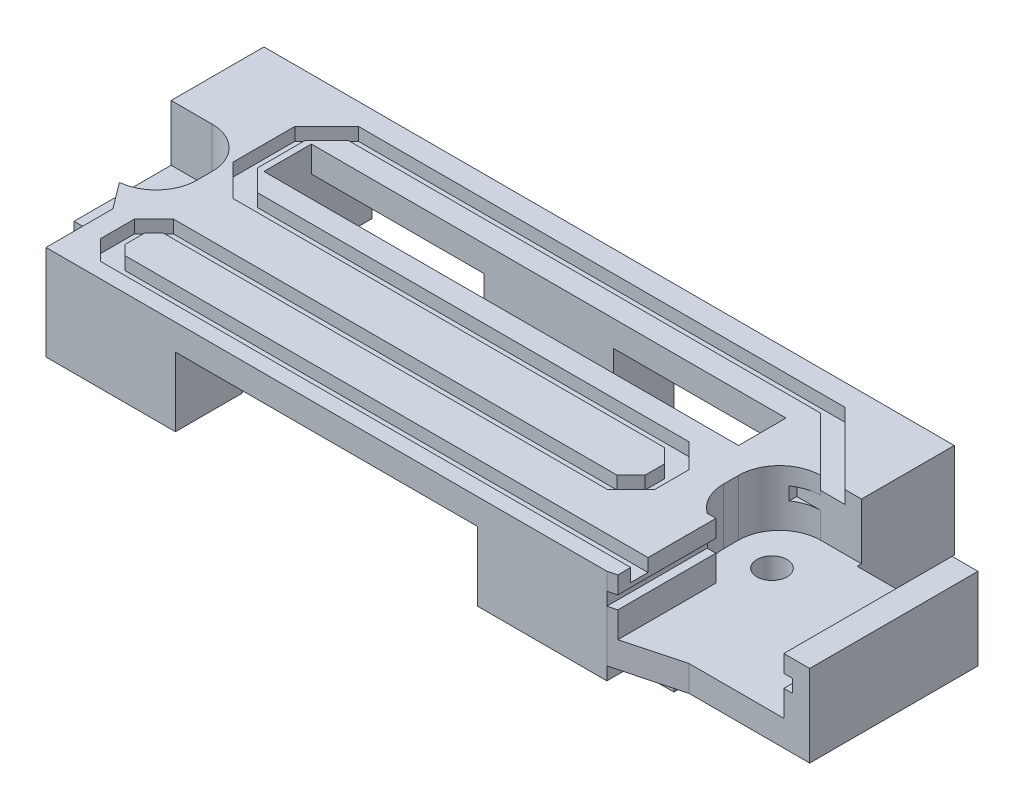
from build123d import *

# Parameters (mm, degrees)
BOSS_EXTRUDE1_DEPTH = 16
SKETCH2_W           = 15
SKETCH2_H           = 7.75
SKETCH2_W_2         = 12.5
CUT_EXTRUDE1_DEPTH  = 5
CUT_EXTRUDE4_DEPTH  = 13
SKETCH6_W           = 55
SKETCH6_H           = 5.5
CUT_EXTRUDE5_DEPTH  = 3
SKETCH7_W           = 15
SKETCH7_H           = 7
SKETCH7_H_2         = 3
BOSS_EXTRUDE2_DEPTH = 13.25
SKETCH8_R           = 2.5
CUT_EXTRUDE6_DEPTH  = 15.5
SKETCH9_R           = 1.75
CUT_EXTRUDE7_DEPTH  = 15
SKETCH11_R          = 1.75
BOSS_EXTRUDE3_DEPTH = 3
SKETCH12_W          = 3
SKETCH12_H          = 19.5
BOSS_EXTRUDE4_DEPTH = 6.5
SKETCH13_W          = 1
SKETCH13_H          = 1.5
SKETCH13_W_2        = 18.5
CUT_EXTRUDE9_DEPTH  = 22
CUT_EXTRUDE10_DEPTH = 1.5


with BuildPart() as part:
    # Sketch1 → Boss-Extrude1 (new body)
    with BuildSketch(Plane(origin=(0, 0, 0), x_dir=(1, 0, 0), z_dir=(0, 1, 0))):
        Polygon((0, 0), (-80, 0), (-80, -7.75), (-80, -10.75), (-70.5, -10.75), (-70.5, -22), (-74.75, -22), (-72.5, -25), (-72.5, -32.75), (-7.5, -32.75), (-7.5, -22), (-9.5, -22), (-9.5, -10.75), (0, -10.75), (0, -7.75), align=None)
    extrude(amount=BOSS_EXTRUDE1_DEPTH)

    # Sketch2 → Cut-Extrude1 (cut)
    with BuildSketch(Plane.XZ):
        with Locations((-65, 28.875)):
            Rectangle(SKETCH2_W, SKETCH2_H)
        with Locations((-73.75, 3.875)):
            Rectangle(SKETCH2_W_2, SKETCH2_H)
        with Locations((-15, 28.875)):
            Rectangle(SKETCH2_W, SKETCH2_H)
        with Locations((-6.25, 3.875)):
            Rectangle(SKETCH2_W_2, SKETCH2_H)
    extrude(amount=-CUT_EXTRUDE1_DEPTH, mode=Mode.SUBTRACT)

    # Sketch5 → Cut-Extrude4 (cut)
    with BuildSketch(Plane.XZ):
        Polygon((-67.5, 25), (-67.5, 7.75), (-67.5, 0), (-12.5, 0), (-12.5, 7.75), (-12.5, 25), (-22.5, 25), (-22.5, 32.75), (-57.5, 32.75), (-57.5, 25), align=None)
    extrude(amount=-CUT_EXTRUDE4_DEPTH, mode=Mode.SUBTRACT)

    # Sketch6 → Cut-Extrude5 (cut)
    with BuildSketch(Plane.XZ.offset(-13)):
        with Locations((-40, 9.75)):
            Rectangle(SKETCH6_W, SKETCH6_H)
    extrude(amount=-CUT_EXTRUDE5_DEPTH, mode=Mode.SUBTRACT)

    # Sketch7 → Boss-Extrude2 (add)
    with BuildSketch(Plane.XZ.offset(-13)):
        with Locations((-40, 3.5)):
            Rectangle(SKETCH7_W, SKETCH7_H)
        with Locations((-40, 14)):
            Rectangle(SKETCH7_W, SKETCH7_H_2)
    extrude(amount=BOSS_EXTRUDE2_DEPTH)

    # Sketch8 → Cut-Extrude6 (cut)
    with BuildSketch(Plane(origin=(0, 0, 0), x_dir=(-1, 0, 0), z_dir=(0, 0, -1))):
        with Locations((40, -0.25)):
            Circle(SKETCH8_R)
    extrude(amount=-CUT_EXTRUDE6_DEPTH, mode=Mode.SUBTRACT)

    # Sketch9 → Cut-Extrude7 (cut)
    with BuildSketch(Plane(origin=(-32.5, 0, 0), x_dir=(0, 0, -1), z_dir=(1, 0, 0))):
        with Locations((-3.5, 3.25)):
            Circle(SKETCH9_R)
    extrude(amount=-CUT_EXTRUDE7_DEPTH, mode=Mode.SUBTRACT)

    # Sketch11 → Boss-Extrude3 (add)
    with BuildSketch(Plane(origin=(0, 6.5, 0), x_dir=(-1, 0, 0), z_dir=(0, -1, 0))):
        Polygon((70.5, -10.75), (70.5, -22), (74.75, -22), (80, -22), (80, -10.75), align=None)
        with Locations((75.25, -16.375)):
            Circle(SKETCH11_R, mode=Mode.SUBTRACT)
        Polygon((7.5, -32.75), (7.5, -22), (9.5, -22), (9.5, -10.75), (0, -10.75), (0, -11.25), (-14, -11.25), (-14, -30.75), (0, -30.75), align=None)
        with Locations((4.75, -16.375)):
            Circle(SKETCH11_R, mode=Mode.SUBTRACT)
    extrude(amount=-BOSS_EXTRUDE3_DEPTH)

    # Sketch12 → Boss-Extrude4 (add)
    with BuildSketch(Plane(origin=(0, 9.5, 0), x_dir=(1, 0, 0), z_dir=(0, 1, 0))):
        with BuildLine():
            ThreePointArc((-75.25, -10.75), (-71.891242789, -12.141242789), (-70.5, -15.5))
            Line((-70.5, -15.5), (-70.5, -10.75))
            Line((-70.5, -10.75), (-75.25, -10.75))
        make_face()
        with BuildLine():
            Line((-74.75, -21.973610907), (-74.75, -22))
            Line((-74.75, -22), (-70.5, -22))
            Line((-70.5, -22), (-70.5, -17.25))
            ThreePointArc((-70.5, -17.25), (-71.718888277, -20.427066257), (-74.75, -21.973610907))
        make_face()
        with Locations((12.5, -21)):
            Rectangle(SKETCH12_W, SKETCH12_H)
        with BuildLine():
            Line((-7.5, -32.75), (-6.5, -32.483333333))
            Line((-6.5, -32.483333333), (-6.5, -21.122983346))
            Line((-6.5, -21.122983346), (-7.5, -21.122983346))
            ThreePointArc((-7.5, -21.122983346), (-8.970485754, -19.429449472), (-9.5, -17.25))
            Line((-9.5, -17.25), (-9.5, -22))
            Line((-9.5, -22), (-7.5, -22))
            Line((-7.5, -22), (-7.5, -32.75))
        make_face()
        with BuildLine():
            ThreePointArc((-9.5, -15.5), (-8.108757211, -12.141242789), (-4.75, -10.75))
            Line((-4.75, -10.75), (-9.5, -10.75))
            Line((-9.5, -10.75), (-9.5, -15.5))
        make_face()
    extrude(amount=BOSS_EXTRUDE4_DEPTH)

    # Sketch13 → Cut-Extrude9 (cut)
    with BuildSketch(Plane.XY.offset(32.75)):
        with Locations((11.5, 13.25)):
            Rectangle(SKETCH13_W, SKETCH13_H)
        with Locations((1.75, 13.25)):
            Rectangle(SKETCH13_W_2, SKETCH13_H)
    extrude(amount=-CUT_EXTRUDE9_DEPTH, mode=Mode.SUBTRACT)

    # Sketch14 → Cut-Extrude10 (cut)
    with BuildSketch(Plane(origin=(0, 16, 0), x_dir=(1, 0, 0), z_dir=(0, 1, 0))):
        Polygon((-4.75, -10.75), (-1.921572875, -10.75), (-10.171572875, -2.5), (-38.36287075, -2.5), (-66.554168625, -2.5), (-70.224250191, -6.170081566), (-70.224250191, -13.329918434), (-66.554168625, -17), (-16.554168625, -17), (-14.939672781, -18.614495844), (-14.939672781, -20.897737763), (-16.554168625, -22.512233607), (-67.954977352, -22.512233607), (-70.224250191, -24.781506445), (-70.224250191, -28.721602613), (-67.954977352, -30.990875451), (-6.5, -30.990875451), (-6.5, -28.990875451), (-67.126550228, -28.990875451), (-68.224250191, -27.893175488), (-68.224250191, -25.60993357), (-67.126550228, -24.512233607), (-15.7257415, -24.512233607), (-12.939672781, -21.726164888), (-12.939672781, -17.786068719), (-15.7257415, -15), (-65.7257415, -15), (-68.224250191, -12.50149131), (-68.224250191, -9.75), (-68.224250191, -6.99850869), (-65.7257415, -4.5), (-38.36287075, -4.5), (-11, -4.5), align=None)
    extrude(amount=-CUT_EXTRUDE10_DEPTH, mode=Mode.SUBTRACT)


solid = part.part
